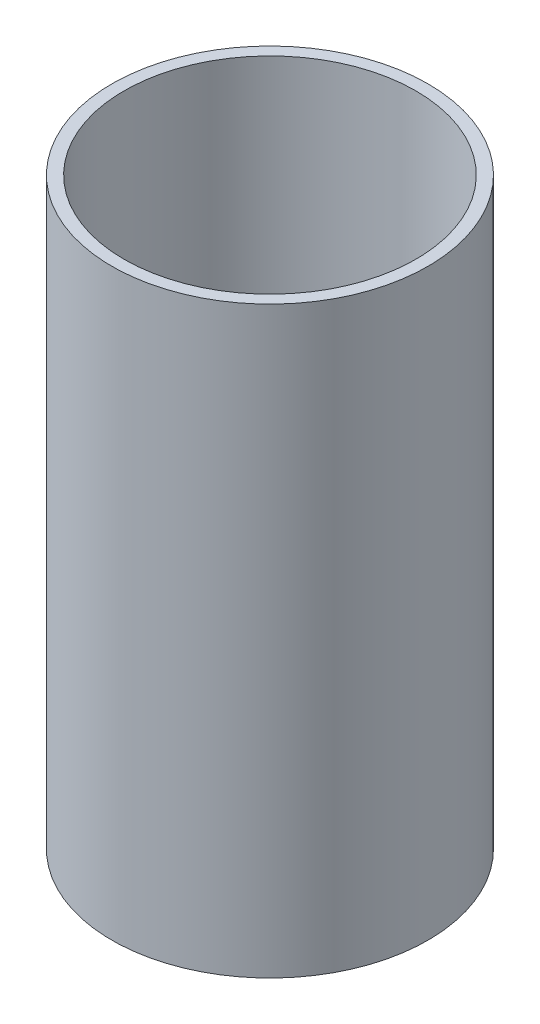
from build123d import *

# Parameters (mm, degrees)
SKETCH1_W = 3.175
SKETCH1_H = 152.4


with BuildPart() as part:
    # Sketch1 → Revolve1 (revolve)
    with BuildSketch(Plane.XY):
        with Locations((-39.6875, 76.2)):
            Rectangle(SKETCH1_W, SKETCH1_H)
    revolve(axis=Axis((0, 0, 0), (0, 1, 0)))


solid = part.part
